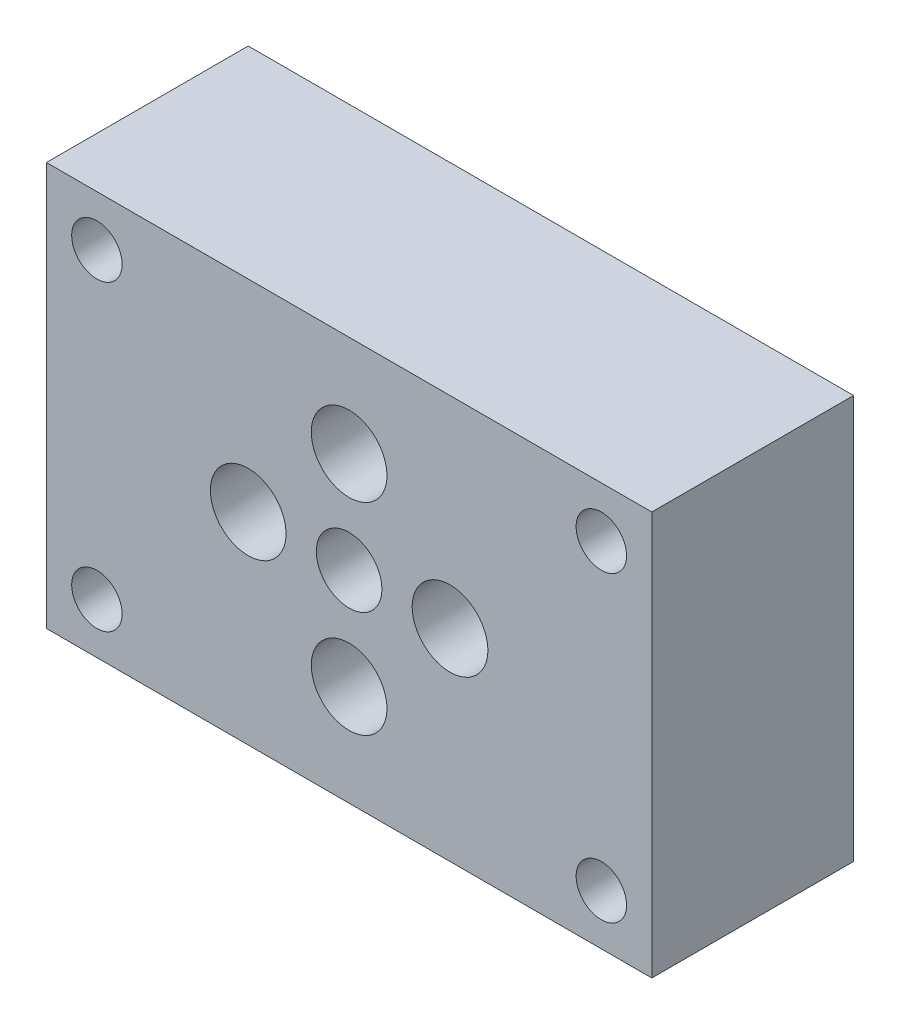
from build123d import *

# Parameters (mm, degrees)
SKETCH_1_W          = 76.2
SKETCH_1_H          = 50.8
EXTRUDE_1_DEPTH     = 25.4
SKETCH_2_R          = 4.1275
CUT_EXTRUDE_1_DEPTH = 25.4
SKETCH_3_R          = 3.175
CUT_EXTRUDE_2_DEPTH = 26.4
SKETCH_4_R          = 3.175
CUT_EXTRUDE_3_DEPTH = 25.4
SKETCH_5_R          = 4.7625
CUT_EXTRUDE_4_DEPTH = 25.4
SKETCH_6_R          = 4.7625
CUT_EXTRUDE_5_DEPTH = 25.4


with BuildPart() as part:
    # 草图1 → 凸台-拉伸1 (new body)
    with BuildSketch(Plane.XY):
        Rectangle(SKETCH_1_W, SKETCH_1_H)
    extrude(amount=-EXTRUDE_1_DEPTH)

    # 草图2 → 切除-拉伸1 (cut)
    with BuildSketch(Plane.XY):
        Circle(SKETCH_2_R)
    extrude(amount=-CUT_EXTRUDE_1_DEPTH, mode=Mode.SUBTRACT)

    # 草图3 → 切除-拉伸2 (cut, through all)
    with BuildSketch(Plane(origin=(0, 0, -25.4), x_dir=(-1, 0, 0), z_dir=(0, 0, -1))):
        with Locations((-31.75, 19.05)):
            Circle(SKETCH_3_R)
        with Locations((31.75, 19.05)):
            Circle(SKETCH_3_R)
    extrude(amount=-CUT_EXTRUDE_2_DEPTH, mode=Mode.SUBTRACT)

    # 草图4 → 切除-拉伸3 (cut)
    with BuildSketch(Plane(origin=(0, 0, -25.4), x_dir=(-1, 0, 0), z_dir=(0, 0, -1))):
        with Locations((-31.75, -19.05)):
            Circle(SKETCH_4_R)
        with Locations((31.75, -19.05)):
            Circle(SKETCH_4_R)
    extrude(amount=-CUT_EXTRUDE_3_DEPTH, mode=Mode.SUBTRACT)

    # 草图5 → 切除-拉伸4 (cut)
    with BuildSketch(Plane(origin=(0, 0, -25.4), x_dir=(-1, 0, 0), z_dir=(0, 0, -1))):
        with Locations((0, 12.7)):
            Circle(SKETCH_5_R)
        with Locations((0, -12.7)):
            Circle(SKETCH_5_R)
    extrude(amount=-CUT_EXTRUDE_4_DEPTH, mode=Mode.SUBTRACT)

    # 草图6 → 切除-拉伸5 (cut)
    with BuildSketch(Plane(origin=(0, 0, -25.4), x_dir=(-1, 0, 0), z_dir=(0, 0, -1))):
        with Locations((-12.7, 0)):
            Circle(SKETCH_6_R)
        with Locations((12.7, 0)):
            Circle(SKETCH_6_R)
    extrude(amount=-CUT_EXTRUDE_5_DEPTH, mode=Mode.SUBTRACT)


solid = part.part
